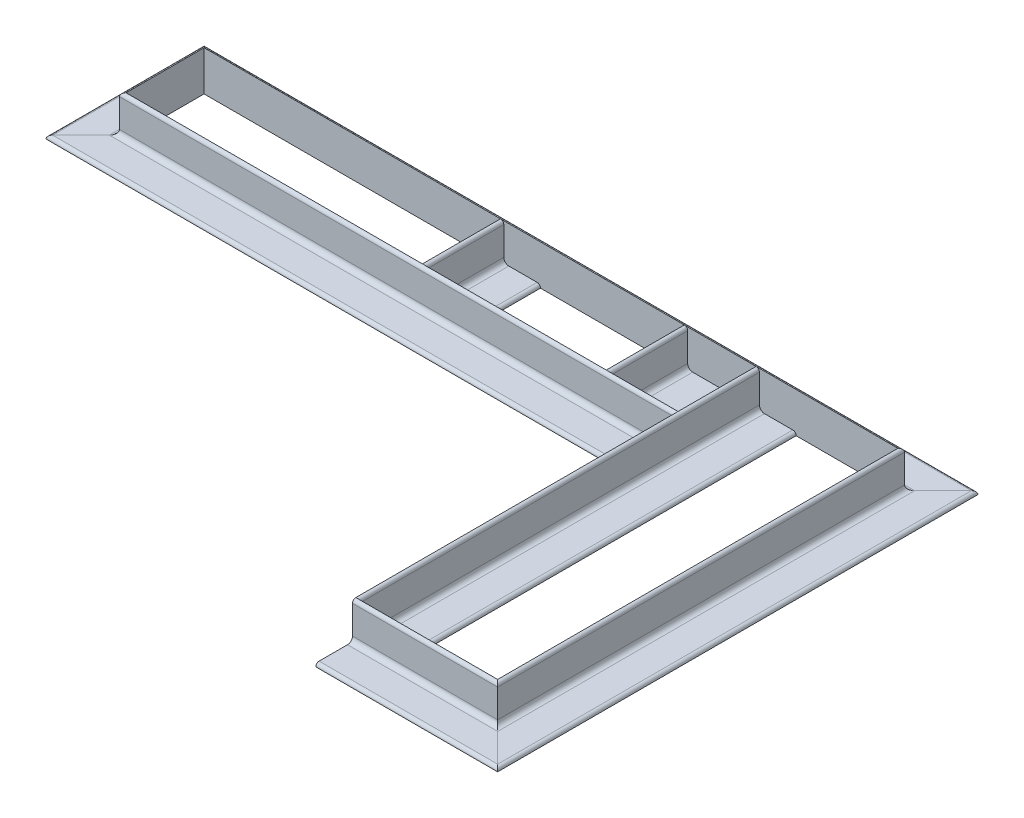
from build123d import *

# Parameters (mm, degrees)
STRUCTURAL_MEMBER4_DEPTH        = 580.281536726
STRUCTURAL_MEMBER4_2_DEPTH      = 184.04273572
STRUCTURAL_MEMBER4_3_DEPTH      = 770.163073453
STRUCTURAL_MEMBER4_4_DEPTH      = 435.881536726
STRUCTURAL_MEMBER4_4_DEPTH_BACK = 54.881536726
STRUCTURAL_MEMBER4_5_DEPTH      = 189.881536726
STRUCTURAL_MEMBER5_DEPTH        = 381
STRUCTURAL_MEMBER5_2_DEPTH      = 74.279662267
STRUCTURAL_MEMBER5_3_DEPTH      = 74.279662267


with BuildPart() as part:
    # Sketch114 on segment 1 (carried to segment 1) → Structural Member4 (new body)
    with BuildSketch(Plane(origin=(195.2, 0, -116.220337733), x_dir=(0, 0, 1), z_dir=(-1, 0, 0))):
        with BuildLine():
            Line((0, 0), (0, 38.1))
            Line((0, 38.1), (0.00508, 38.1))
            ThreePointArc((0.00508, 38.1), (2.246551928, 37.171551928), (3.175, 34.93008))
            Line((3.175, 34.93008), (3.175, 7.9502))
            ThreePointArc((3.175, 7.9502), (4.573623698, 4.573623698), (7.9502, 3.175))
            Line((7.9502, 3.175), (34.93008, 3.175))
            ThreePointArc((34.93008, 3.175), (37.171551928, 2.246551928), (38.1, 0.00508))
            Line((38.1, 0.00508), (38.1, 0))
            Line((38.1, 0), (0, 0))
        make_face()
    extrude(amount=STRUCTURAL_MEMBER4_DEPTH)

    # Structural Member4 mitre 1
    split(bisect_by=Plane(origin=(-330.2, 0, -116.220337733), x_dir=(0, 1, 0), z_dir=(0.707106781, 0, 0.707106781)), keep=Keep.TOP)


with BuildPart() as body_2:
    # Sketch114 on segment 2 (carried to segment 2) → Structural Member4 2 (new body)
    with BuildSketch(Plane(origin=(-330.2, 0, -61.338801007), x_dir=(-1, 0, 0), z_dir=(0, 0, -1))):
        with BuildLine():
            Line((0, 0), (0, 38.1))
            Line((0, 38.1), (0.00508, 38.1))
            ThreePointArc((0.00508, 38.1), (2.246551928, 37.171551928), (3.175, 34.93008))
            Line((3.175, 34.93008), (3.175, 7.9502))
            ThreePointArc((3.175, 7.9502), (4.573623698, 4.573623698), (7.9502, 3.175))
            Line((7.9502, 3.175), (34.93008, 3.175))
            ThreePointArc((34.93008, 3.175), (37.171551928, 2.246551928), (38.1, 0.00508))
            Line((38.1, 0.00508), (38.1, 0))
            Line((38.1, 0), (0, 0))
        make_face()
    extrude(amount=STRUCTURAL_MEMBER4_2_DEPTH)

    # Structural Member4 2 mitre 1
    split(bisect_by=Plane(origin=(-330.2, 0, -190.5), x_dir=(0, -1, 0), z_dir=(-0.707106781, 0, 0.707106781)), keep=Keep.TOP)

    # Structural Member4 2 mitre 2
    split(bisect_by=Plane(origin=(-330.2, 0, -116.220337733), x_dir=(0, -1, 0), z_dir=(-0.707106781, 0, -0.707106781)), keep=Keep.TOP)


with BuildPart() as body_3:
    # Sketch114 on segment 3 (carried to segment 3) → Structural Member4 3 (new body)
    with BuildSketch(Plane(origin=(-385.081536726, 0, -190.5), x_dir=(0, 0, -1), z_dir=(1, 0, 0))):
        with BuildLine():
            Line((0, 0), (0, 38.1))
            Line((0, 38.1), (0.00508, 38.1))
            ThreePointArc((0.00508, 38.1), (2.246551928, 37.171551928), (3.175, 34.93008))
            Line((3.175, 34.93008), (3.175, 7.9502))
            ThreePointArc((3.175, 7.9502), (4.573623698, 4.573623698), (7.9502, 3.175))
            Line((7.9502, 3.175), (34.93008, 3.175))
            ThreePointArc((34.93008, 3.175), (37.171551928, 2.246551928), (38.1, 0.00508))
            Line((38.1, 0.00508), (38.1, 0))
            Line((38.1, 0), (0, 0))
        make_face()
    extrude(amount=STRUCTURAL_MEMBER4_3_DEPTH)

    # Structural Member4 3 mitre 1
    split(bisect_by=Plane(origin=(-330.2, 0, -190.5), x_dir=(0, 1, 0), z_dir=(0.707106781, 0, -0.707106781)), keep=Keep.TOP)

    # Structural Member4 3 mitre 2
    split(bisect_by=Plane(origin=(330.2, 0, -190.5), x_dir=(0, -1, 0), z_dir=(-0.707106781, 0, -0.707106781)), keep=Keep.TOP)


with BuildPart() as body_4:
    # Sketch114 → Structural Member4 4 (new, two sides)
    with BuildSketch(Plane(origin=(330.2, 0, -190.5), x_dir=(1, 0, 0), z_dir=(0, 0, 1))) as structural_member4_4_sk:
        with BuildLine():
            Line((0, 0), (0, 38.1))
            Line((0, 38.1), (0.00508, 38.1))
            ThreePointArc((0.00508, 38.1), (2.246551928, 37.171551928), (3.175, 34.93008))
            Line((3.175, 34.93008), (3.175, 7.9502))
            ThreePointArc((3.175, 7.9502), (4.573623698, 4.573623698), (7.9502, 3.175))
            Line((7.9502, 3.175), (34.93008, 3.175))
            ThreePointArc((34.93008, 3.175), (37.171551928, 2.246551928), (38.1, 0.00508))
            Line((38.1, 0.00508), (38.1, 0))
            Line((38.1, 0), (0, 0))
        make_face()
    extrude(amount=STRUCTURAL_MEMBER4_4_DEPTH)
    extrude(structural_member4_4_sk.sketch, amount=-STRUCTURAL_MEMBER4_4_DEPTH_BACK)

    # Structural Member4 4 mitre 1
    split(bisect_by=Plane(origin=(330.2, 0, -190.5), x_dir=(0, 1, 0), z_dir=(0.707106781, 0, 0.707106781)), keep=Keep.TOP)

    # Structural Member4 4 mitre 2
    split(bisect_by=Plane(origin=(330.2, 0, 190.5), x_dir=(0, 1, 0), z_dir=(0.707106781, 0, -0.707106781)), keep=Keep.TOP)


with BuildPart() as body_5:
    # Sketch114 on segment 5 (carried to segment 5) → Structural Member4 5 (new body)
    with BuildSketch(Plane(origin=(385.081536726, 0, 190.5), x_dir=(0, 0, 1), z_dir=(-1, 0, 0))):
        with BuildLine():
            Line((0, 0), (0, 38.1))
            Line((0, 38.1), (0.00508, 38.1))
            ThreePointArc((0.00508, 38.1), (2.246551928, 37.171551928), (3.175, 34.93008))
            Line((3.175, 34.93008), (3.175, 7.9502))
            ThreePointArc((3.175, 7.9502), (4.573623698, 4.573623698), (7.9502, 3.175))
            Line((7.9502, 3.175), (34.93008, 3.175))
            ThreePointArc((34.93008, 3.175), (37.171551928, 2.246551928), (38.1, 0.00508))
            Line((38.1, 0.00508), (38.1, 0))
            Line((38.1, 0), (0, 0))
        make_face()
    extrude(amount=STRUCTURAL_MEMBER4_5_DEPTH)

    # Structural Member4 5 mitre 1
    split(bisect_by=Plane(origin=(330.2, 0, 190.5), x_dir=(0, -1, 0), z_dir=(-0.707106781, 0, 0.707106781)), keep=Keep.TOP)


with BuildPart() as body_6:
    # Sketch115 → Structural Member5 (new body)
    with BuildSketch(Plane(origin=(195.2, 0, -190.5), x_dir=(1, 0, 0), z_dir=(0, 0, 1))):
        with BuildLine():
            Line((0, 0), (0, 38.1))
            Line((0, 38.1), (0.00508, 38.1))
            ThreePointArc((0.00508, 38.1), (2.246551928, 37.171551928), (3.175, 34.93008))
            Line((3.175, 34.93008), (3.175, 7.9502))
            ThreePointArc((3.175, 7.9502), (4.573623698, 4.573623698), (7.9502, 3.175))
            Line((7.9502, 3.175), (34.93008, 3.175))
            ThreePointArc((34.93008, 3.175), (37.171551928, 2.246551928), (38.1, 0.00508))
            Line((38.1, 0.00508), (38.1, 0))
            Line((38.1, 0), (0, 0))
        make_face()
    extrude(amount=STRUCTURAL_MEMBER5_DEPTH)


with BuildPart() as body_7:
    # Sketch115 on segment 2 (carried to segment 2) → Structural Member5 2 (new body)
    with BuildSketch(Plane(origin=(126.879374737, 0, -190.5), x_dir=(1, 0, 0), z_dir=(0, 0, 1))):
        with BuildLine():
            Line((0, 0), (0, 38.1))
            Line((0, 38.1), (0.00508, 38.1))
            ThreePointArc((0.00508, 38.1), (2.246551928, 37.171551928), (3.175, 34.93008))
            Line((3.175, 34.93008), (3.175, 7.9502))
            ThreePointArc((3.175, 7.9502), (4.573623698, 4.573623698), (7.9502, 3.175))
            Line((7.9502, 3.175), (34.93008, 3.175))
            ThreePointArc((34.93008, 3.175), (37.171551928, 2.246551928), (38.1, 0.00508))
            Line((38.1, 0.00508), (38.1, 0))
            Line((38.1, 0), (0, 0))
        make_face()
    extrude(amount=STRUCTURAL_MEMBER5_2_DEPTH)


with BuildPart() as body_8:
    # Sketch115 on segment 3 (carried to segment 3) → Structural Member5 3 (new body)
    with BuildSketch(Plane(origin=(-48.120625263, 0, -190.5), x_dir=(1, 0, 0), z_dir=(0, 0, 1))):
        with BuildLine():
            Line((0, 0), (0, 38.1))
            Line((0, 38.1), (0.00508, 38.1))
            ThreePointArc((0.00508, 38.1), (2.246551928, 37.171551928), (3.175, 34.93008))
            Line((3.175, 34.93008), (3.175, 7.9502))
            ThreePointArc((3.175, 7.9502), (4.573623698, 4.573623698), (7.9502, 3.175))
            Line((7.9502, 3.175), (34.93008, 3.175))
            ThreePointArc((34.93008, 3.175), (37.171551928, 2.246551928), (38.1, 0.00508))
            Line((38.1, 0.00508), (38.1, 0))
            Line((38.1, 0), (0, 0))
        make_face()
    extrude(amount=STRUCTURAL_MEMBER5_3_DEPTH)


solid = Compound([part.part, body_2.part, body_3.part, body_4.part, body_5.part, body_6.part, body_7.part, body_8.part])
